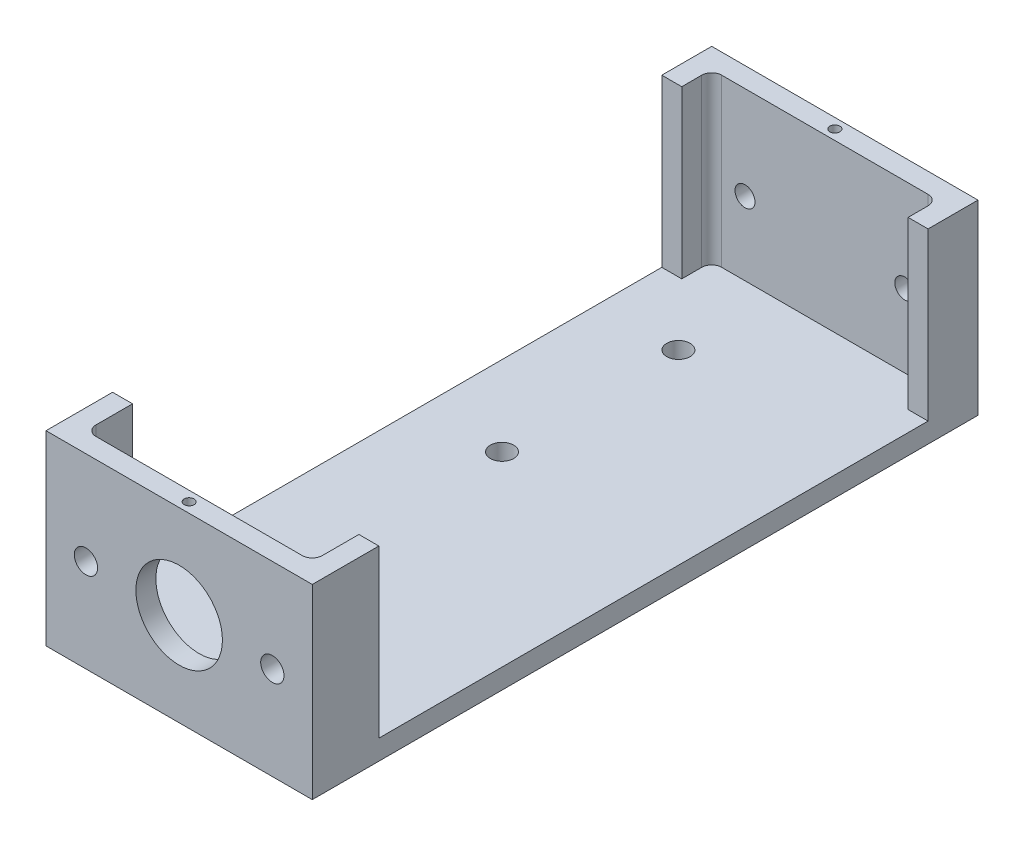
from build123d import *

# Parameters (mm, degrees)
SKETCH_1_W          = 80
SKETCH_1_H          = 56
EXTRUDE_1_DEPTH     = 200
CUT_EXTRUDE_1_DEPTH = 50
SKETCH_3_R          = 3.5
SKETCH_3_R_2        = 13
CUT_EXTRUDE_2_DEPTH = 10
SKETCH_4_R          = 2
SKETCH_4_W          = 27
SKETCH_4_H          = 36
CUT_EXTRUDE_3_DEPTH = 10
SKETCH_5_R          = 3
CUT_EXTRUDE_4_DEPTH = 10
SKETCH_6_R          = 3.500000002
SKETCH_6_R_2        = 3.5
CUT_EXTRUDE_5_DEPTH = 10
SKETCH_7_R          = 1.5
CUT_EXTRUDE_6_DEPTH = 10
SKETCH_8_W          = 165
SKETCH_8_H          = 50
CUT_EXTRUDE_7_DEPTH = 81


with BuildPart() as part:
    # 草图1 → 凸台-拉伸1 (new body)
    with BuildSketch(Plane.XY):
        Rectangle(SKETCH_1_W, SKETCH_1_H)
    extrude(amount=-EXTRUDE_1_DEPTH)

    # 草图2 → 切除-拉伸1 (cut)
    with BuildSketch(Plane(origin=(0, 28, 0), x_dir=(1, 0, 0), z_dir=(0, 1, 0))):
        with BuildLine():
            ThreePointArc((-34, 191), (-33.121320344, 193.121320344), (-31, 194))
            Line((-31, 194), (31, 194))
            ThreePointArc((31, 194), (33.121320344, 193.121320344), (34, 191))
            Line((34, 191), (34, 9))
            ThreePointArc((34, 9), (33.121320344, 6.878679656), (31, 6))
            Line((31, 6), (-31, 6))
            ThreePointArc((-31, 6), (-33.121320344, 6.878679656), (-34, 9))
            Line((-34, 9), (-34, 191))
        make_face()
    extrude(amount=-CUT_EXTRUDE_1_DEPTH, mode=Mode.SUBTRACT)

    # 草图3 → 切除-拉伸2 (cut)
    with BuildSketch(Plane.XY):
        with Locations((-28, 0)):
            Circle(SKETCH_3_R)
        Circle(SKETCH_3_R_2)
        with Locations((28, 0)):
            Circle(SKETCH_3_R)
    extrude(amount=-CUT_EXTRUDE_2_DEPTH, mode=Mode.SUBTRACT)

    # 草图4 → 切除-拉伸3 (cut)
    with BuildSketch(Plane.ZY.offset(40)):
        with Locations((-121.5, -5)):
            Circle(SKETCH_4_R)
        with Locations((-121.5, 19)):
            Circle(SKETCH_4_R)
        with Locations((-158.5, 19)):
            Circle(SKETCH_4_R)
        with Locations((-158.5, -5)):
            Circle(SKETCH_4_R)
        with Locations((-140, 7)):
            Rectangle(SKETCH_4_W, SKETCH_4_H)
    extrude(amount=-CUT_EXTRUDE_3_DEPTH, mode=Mode.SUBTRACT)

    # 草图5 → 切除-拉伸4 (cut)
    with BuildSketch(Plane(origin=(0, 0, -200), x_dir=(-1, 0, 0), z_dir=(0, 0, -1))):
        with Locations((24, 0)):
            Circle(SKETCH_5_R)
        with Locations((-24, 0)):
            Circle(SKETCH_5_R)
    extrude(amount=-CUT_EXTRUDE_4_DEPTH, mode=Mode.SUBTRACT)

    # 草图6 → 切除-拉伸5 (cut)
    with BuildSketch(Plane(origin=(0, -22, 0), x_dir=(1, 0, 0), z_dir=(0, 1, 0))):
        with Locations((-16, 166)):
            Circle(SKETCH_6_R)
        with Locations((-16, 113)):
            Circle(SKETCH_6_R_2)
    extrude(amount=-CUT_EXTRUDE_5_DEPTH, mode=Mode.SUBTRACT)

    # 草图7 → 切除-拉伸6 (cut)
    with BuildSketch(Plane(origin=(0, 28, 0), x_dir=(1, 0, 0), z_dir=(0, 1, 0))):
        with Locations((-37, 150)):
            Circle(SKETCH_7_R)
        with Locations((-37, 50)):
            Circle(SKETCH_7_R)
        with Locations((37, 50)):
            Circle(SKETCH_7_R)
        with Locations((37, 150)):
            Circle(SKETCH_7_R)
        with Locations((0, 197)):
            Circle(SKETCH_7_R)
        with Locations((0, 3)):
            Circle(SKETCH_7_R)
    extrude(amount=-CUT_EXTRUDE_6_DEPTH, mode=Mode.SUBTRACT)

    # 草图8 → 切除-拉伸7 (cut, through all)
    with BuildSketch(Plane(origin=(40, 0, 0), x_dir=(0, 0, -1), z_dir=(1, 0, 0))):
        with Locations((102.5, 3)):
            Rectangle(SKETCH_8_W, SKETCH_8_H)
    extrude(amount=-CUT_EXTRUDE_7_DEPTH, mode=Mode.SUBTRACT)


solid = part.part
